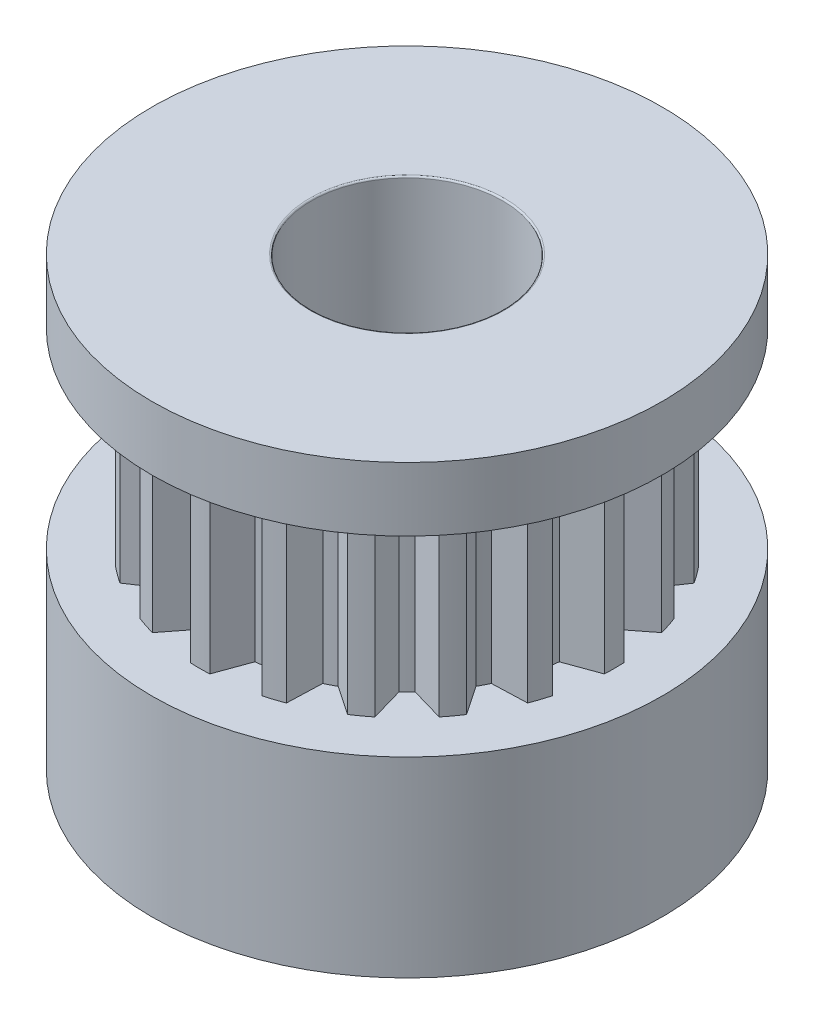
from build123d import *

# Parameters (mm, degrees)
SKETCH1_R           = 8
BOSS_EXTRUDE1_DEPTH = 6
BOSS_EXTRUDE2_DEPTH = 6
SKETCH3_R           = 8
BOSS_EXTRUDE3_DEPTH = 2
SKETCH4_R           = 3
CUT_EXTRUDE1_DEPTH  = 15
SKETCH5_R           = 4
CUT_EXTRUDE2_DEPTH  = 0.3
FILLET1_R           = 0.05


with BuildPart() as part:
    # Sketch1 → Boss-Extrude1 (new body)
    with BuildSketch(Plane(origin=(0, 0, 0), x_dir=(1, 0, 0), z_dir=(0, 1, 0))):
        Circle(SKETCH1_R)
    extrude(amount=-BOSS_EXTRUDE1_DEPTH)

    # Sketch2 → Boss-Extrude2 (add)
    with BuildSketch(Plane(origin=(0, 0, 0), x_dir=(1, 0, 0), z_dir=(0, 1, 0))):
        with BuildLine():
            Line((-0.305930382, 6.492796516), (-0.682763233, 5.457456767))
            ThreePointArc((-0.682763233, 5.457456767), (-0.860389558, 5.432285873), (-1.037100465, 5.401335263))
            Line((-1.037100465, 5.401335263), (-1.715427381, 6.269554123))
            ThreePointArc((-1.715427381, 6.269554123), (-2.008610463, 6.181867356), (-2.297341548, 6.080478749))
            Line((-2.297341548, 6.080478749), (-2.335793309, 4.979364379))
            ThreePointArc((-2.335793309, 4.979364379), (-2.496947749, 4.900535883), (-2.655445544, 4.81649343))
            Line((-2.655445544, 4.81649343), (-3.56886716, 5.43260409))
            ThreePointArc((-3.56886716, 5.43260409), (-3.82060414, 5.258610463), (-4.063872917, 5.072961356))
            Line((-4.063872917, 5.072961356), (-3.760179662, 4.013857112))
            ThreePointArc((-3.760179662, 4.013857112), (-3.889087297, 3.889087297), (-4.013857112, 3.760179662))
            Line((-4.013857112, 3.760179662), (-5.072961356, 4.063872917))
            ThreePointArc((-5.072961356, 4.063872917), (-5.258610463, 3.82060414), (-5.43260409, 3.56886716))
            Line((-5.43260409, 3.56886716), (-4.81649343, 2.655445544))
            ThreePointArc((-4.81649343, 2.655445544), (-4.900535883, 2.496947749), (-4.979364379, 2.335793309))
            Line((-4.979364379, 2.335793309), (-6.080478749, 2.297341548))
            ThreePointArc((-6.080478749, 2.297341548), (-6.181867356, 2.008610463), (-6.269554123, 1.715427381))
            Line((-6.269554123, 1.715427381), (-5.401335263, 1.037100465))
            ThreePointArc((-5.401335263, 1.037100465), (-5.432285873, 0.860389558), (-5.457456767, 0.682763233))
            Line((-5.457456767, 0.682763233), (-6.492796516, 0.305930382))
            ThreePointArc((-6.492796516, 0.305930382), (-6.5, 0), (-6.492796516, -0.305930382))
            Line((-6.492796516, -0.305930382), (-5.457456767, -0.682763233))
            ThreePointArc((-5.457456767, -0.682763233), (-5.432285873, -0.860389558), (-5.401335263, -1.037100465))
            Line((-5.401335263, -1.037100465), (-6.269554123, -1.715427381))
            ThreePointArc((-6.269554123, -1.715427381), (-6.181867356, -2.008610463), (-6.080478749, -2.297341548))
            Line((-6.080478749, -2.297341548), (-4.979364379, -2.335793309))
            ThreePointArc((-4.979364379, -2.335793309), (-4.900535883, -2.496947749), (-4.81649343, -2.655445544))
            Line((-4.81649343, -2.655445544), (-5.43260409, -3.56886716))
            ThreePointArc((-5.43260409, -3.56886716), (-5.258610463, -3.82060414), (-5.072961356, -4.063872917))
            Line((-5.072961356, -4.063872917), (-4.013857112, -3.760179662))
            ThreePointArc((-4.013857112, -3.760179662), (-3.889087297, -3.889087297), (-3.760179662, -4.013857112))
            Line((-3.760179662, -4.013857112), (-4.063872917, -5.072961356))
            ThreePointArc((-4.063872917, -5.072961356), (-3.82060414, -5.258610463), (-3.56886716, -5.43260409))
            Line((-3.56886716, -5.43260409), (-2.655445544, -4.81649343))
            ThreePointArc((-2.655445544, -4.81649343), (-2.496947749, -4.900535883), (-2.335793309, -4.979364379))
            Line((-2.335793309, -4.979364379), (-2.297341548, -6.080478749))
            ThreePointArc((-2.297341548, -6.080478749), (-2.008610463, -6.181867356), (-1.715427381, -6.269554123))
            Line((-1.715427381, -6.269554123), (-1.037100465, -5.401335263))
            ThreePointArc((-1.037100465, -5.401335263), (-0.860389558, -5.432285873), (-0.682763233, -5.457456767))
            Line((-0.682763233, -5.457456767), (-0.305930382, -6.492796516))
            ThreePointArc((-0.305930382, -6.492796516), (0, -6.5), (0.305930382, -6.492796516))
            Line((0.305930382, -6.492796516), (0.682763233, -5.457456767))
            ThreePointArc((0.682763233, -5.457456767), (0.860389558, -5.432285873), (1.037100465, -5.401335263))
            Line((1.037100465, -5.401335263), (1.715427381, -6.269554123))
            ThreePointArc((1.715427381, -6.269554123), (2.008610463, -6.181867356), (2.297341548, -6.080478749))
            Line((2.297341548, -6.080478749), (2.335793309, -4.979364379))
            ThreePointArc((2.335793309, -4.979364379), (2.496947749, -4.900535883), (2.655445544, -4.81649343))
            Line((2.655445544, -4.81649343), (3.56886716, -5.43260409))
            ThreePointArc((3.56886716, -5.43260409), (3.82060414, -5.258610463), (4.063872917, -5.072961356))
            Line((4.063872917, -5.072961356), (3.760179662, -4.013857112))
            ThreePointArc((3.760179662, -4.013857112), (3.889087297, -3.889087297), (4.013857112, -3.760179662))
            Line((4.013857112, -3.760179662), (5.072961356, -4.063872917))
            ThreePointArc((5.072961356, -4.063872917), (5.258610463, -3.82060414), (5.43260409, -3.56886716))
            Line((5.43260409, -3.56886716), (4.81649343, -2.655445544))
            ThreePointArc((4.81649343, -2.655445544), (4.900535883, -2.496947749), (4.979364379, -2.335793309))
            Line((4.979364379, -2.335793309), (6.080478749, -2.297341548))
            ThreePointArc((6.080478749, -2.297341548), (6.181867356, -2.008610463), (6.269554123, -1.715427381))
            Line((6.269554123, -1.715427381), (5.401335263, -1.037100465))
            ThreePointArc((5.401335263, -1.037100465), (5.432285873, -0.860389558), (5.457456767, -0.682763233))
            Line((5.457456767, -0.682763233), (6.492796516, -0.305930382))
            ThreePointArc((6.492796516, -0.305930382), (6.5, 0), (6.492796516, 0.305930382))
            Line((6.492796516, 0.305930382), (5.457456767, 0.682763233))
            ThreePointArc((5.457456767, 0.682763233), (5.432285873, 0.860389558), (5.401335263, 1.037100465))
            Line((5.401335263, 1.037100465), (6.269554123, 1.715427381))
            ThreePointArc((6.269554123, 1.715427381), (6.181867356, 2.008610463), (6.080478749, 2.297341548))
            Line((6.080478749, 2.297341548), (4.979364379, 2.335793309))
            ThreePointArc((4.979364379, 2.335793309), (4.900535883, 2.496947749), (4.81649343, 2.655445544))
            Line((4.81649343, 2.655445544), (5.43260409, 3.56886716))
            ThreePointArc((5.43260409, 3.56886716), (5.258610463, 3.82060414), (5.072961356, 4.063872917))
            Line((5.072961356, 4.063872917), (4.013857112, 3.760179662))
            ThreePointArc((4.013857112, 3.760179662), (3.889087297, 3.889087297), (3.760179662, 4.013857112))
            Line((3.760179662, 4.013857112), (4.063872917, 5.072961356))
            ThreePointArc((4.063872917, 5.072961356), (3.82060414, 5.258610463), (3.56886716, 5.43260409))
            Line((3.56886716, 5.43260409), (2.655445544, 4.81649343))
            ThreePointArc((2.655445544, 4.81649343), (2.496947749, 4.900535883), (2.335793309, 4.979364379))
            Line((2.335793309, 4.979364379), (2.297341548, 6.080478749))
            ThreePointArc((2.297341548, 6.080478749), (2.008610463, 6.181867356), (1.715427381, 6.269554123))
            Line((1.715427381, 6.269554123), (1.037100465, 5.401335263))
            ThreePointArc((1.037100465, 5.401335263), (0.860389558, 5.432285873), (0.682763233, 5.457456767))
            Line((0.682763233, 5.457456767), (0.305930382, 6.492796516))
            ThreePointArc((0.305930382, 6.492796516), (0, 6.5), (-0.305930382, 6.492796516))
        make_face()
    extrude(amount=BOSS_EXTRUDE2_DEPTH)

    # Sketch3 → Boss-Extrude3 (add)
    with BuildSketch(Plane(origin=(0, 6, 0), x_dir=(1, 0, 0), z_dir=(0, 1, 0))):
        Circle(SKETCH3_R)
    extrude(amount=BOSS_EXTRUDE3_DEPTH)

    # Sketch4 → Cut-Extrude1 (cut, through all)
    with BuildSketch(Plane.XZ.offset(6)):
        Circle(SKETCH4_R)
    extrude(amount=-CUT_EXTRUDE1_DEPTH, mode=Mode.SUBTRACT)

    # Sketch5 → Cut-Extrude2 (cut)
    with BuildSketch(Plane.XZ.offset(6)):
        Circle(SKETCH5_R)
    extrude(amount=-CUT_EXTRUDE2_DEPTH, mode=Mode.SUBTRACT)

    # Fillet1
    fillet1_edges = [part.edges().sort_by_distance(p)[0] for p in [
        (-3, 8, 0),
        (-3, -5.7, 0),
    ]]
    fillet(fillet1_edges, radius=FILLET1_R)


solid = part.part
